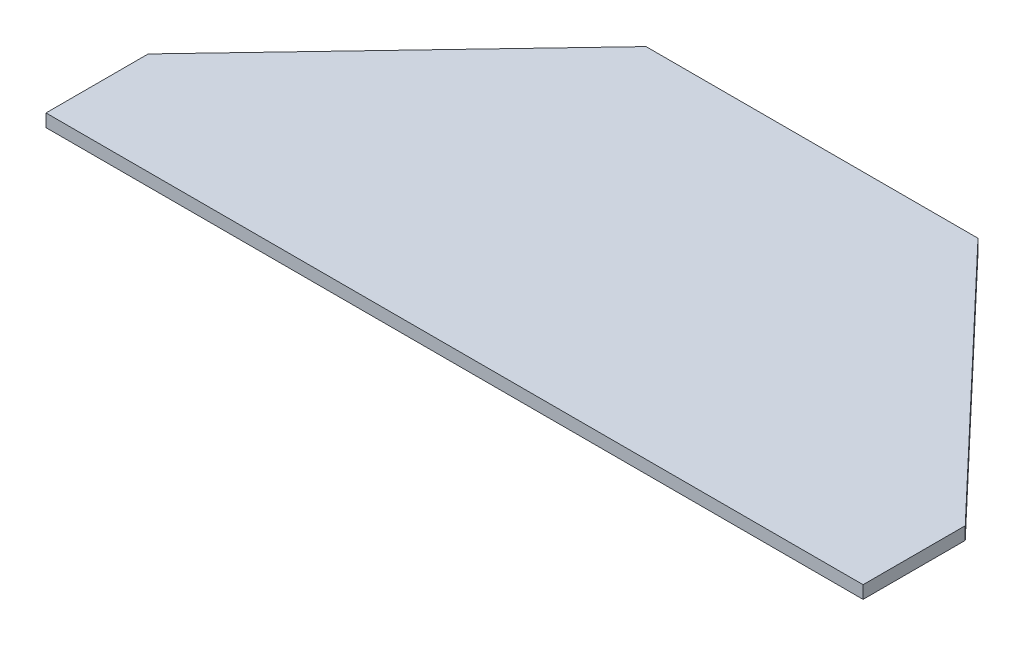
from build123d import *

# Parameters (mm, degrees)
BOSS_EXTRUDE1_DEPTH = 3.175


with BuildPart() as part:
    # Sketch1 → Boss-Extrude1 (new body, symmetric)
    with BuildSketch(Plane(origin=(0, 0, 0), x_dir=(1, 0, 0), z_dir=(0, 1, 0))):
        Polygon((-203.2, 0), (203.2, 0), (203.2, 50.8), (82.55, 177.8), (-82.55, 177.8), (-203.2, 50.8), align=None)
    extrude(amount=BOSS_EXTRUDE1_DEPTH, both=True)


solid = part.part
